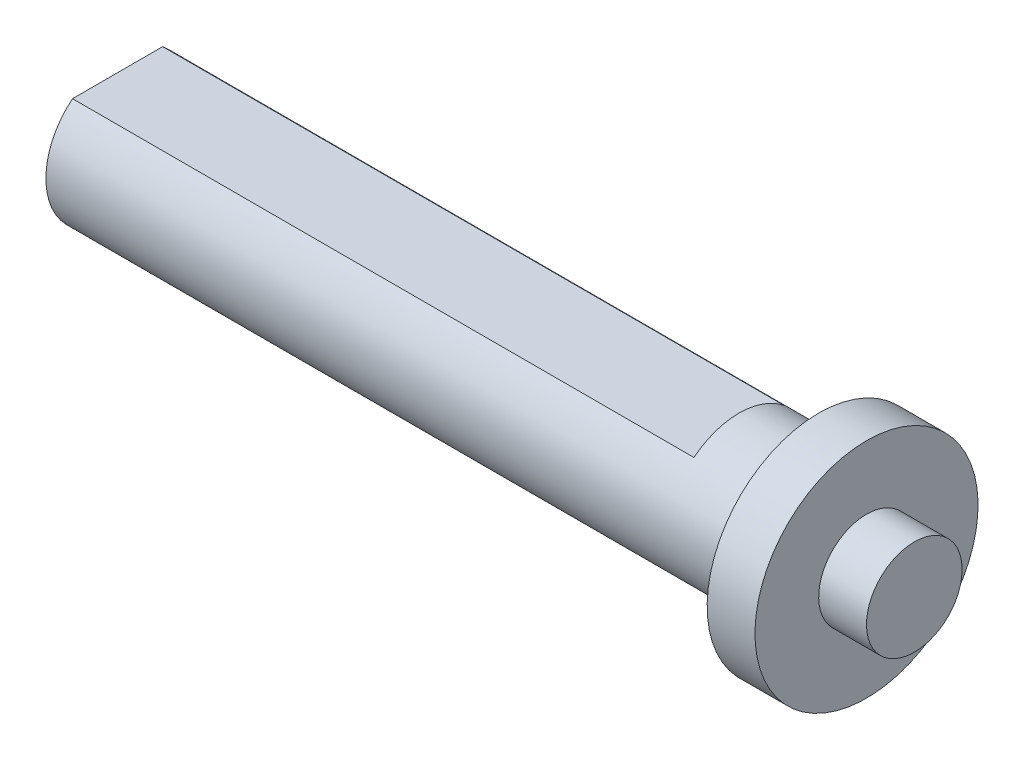
from build123d import *

# Parameters (mm, degrees)
SKETCH_1_W          = 44
SKETCH_1_H          = 4.5
SKETCH_1_W_2        = 3
SKETCH_1_H_2        = 7
SKETCH_1_H_3        = 3
SKETCH_5_W          = 39
SKETCH_5_H          = 1
CUT_EXTRUDE_2_DEPTH = 5


with BuildPart() as part:
    # 草圖1 → 旋轉1 (revolve)
    with BuildSketch(Plane.XY):
        with Locations((-22, 2.25)):
            Rectangle(SKETCH_1_W, SKETCH_1_H)
        with Locations((1.5, 3.5)):
            Rectangle(SKETCH_1_W_2, SKETCH_1_H_2)
        with Locations((4.5, 1.5)):
            Rectangle(SKETCH_1_W_2, SKETCH_1_H_3)
    revolve(axis=Axis((0, 0, 0), (-1, 0, 0)))

    # 草圖5 → 除料-伸長2 (cut, symmetric)
    with BuildSketch(Plane.XY):
        with Locations((-24.5, 4)):
            Rectangle(SKETCH_5_W, SKETCH_5_H)
        with Locations((-24.5, -4)):
            Rectangle(SKETCH_5_W, SKETCH_5_H)
    extrude(amount=CUT_EXTRUDE_2_DEPTH, both=True, mode=Mode.SUBTRACT)


solid = part.part
